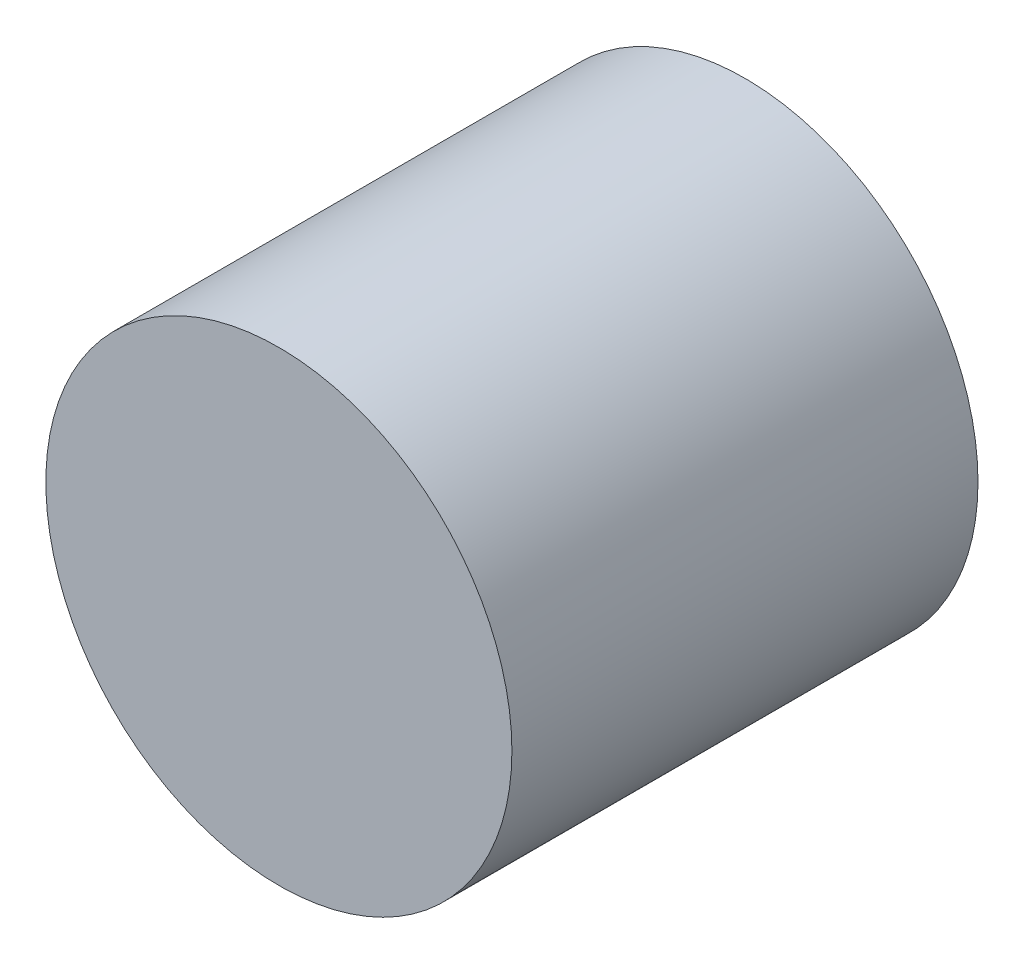
from build123d import *

# Parameters (mm, degrees)
IZIM1_R                     = 3.5
Y_KSEKLIK_EKSTR_ZYON1_DEPTH = 7


with BuildPart() as part:
    # Çizim1 → Yükseklik-Ekstrüzyon1 (new body)
    with BuildSketch(Plane.XY):
        Circle(IZIM1_R)
    extrude(amount=Y_KSEKLIK_EKSTR_ZYON1_DEPTH)


solid = part.part
